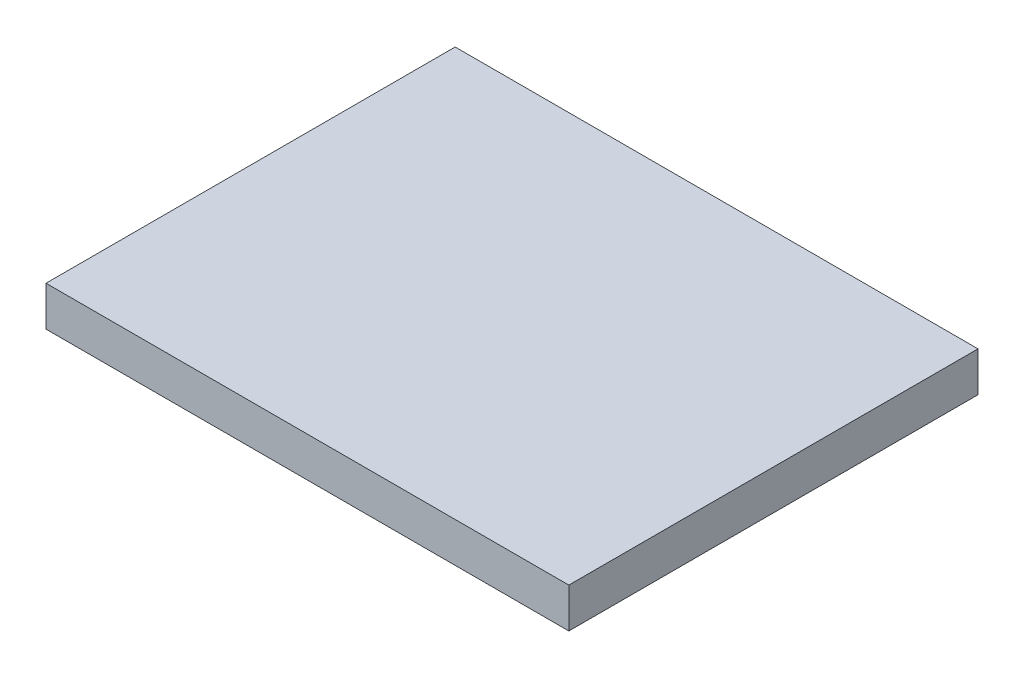
from build123d import *

# Parameters (mm, degrees)
ESQUISSE1_W        = 46
ESQUISSE1_H        = 36
BOSS_EXTRU_1_DEPTH = 3.5


with BuildPart() as part:
    # Esquisse1 → Boss.-Extru.1 (new body)
    with BuildSketch(Plane(origin=(0, 0, 0), x_dir=(1, 0, 0), z_dir=(0, 1, 0))):
        Rectangle(ESQUISSE1_W, ESQUISSE1_H)
    extrude(amount=BOSS_EXTRU_1_DEPTH)


solid = part.part
